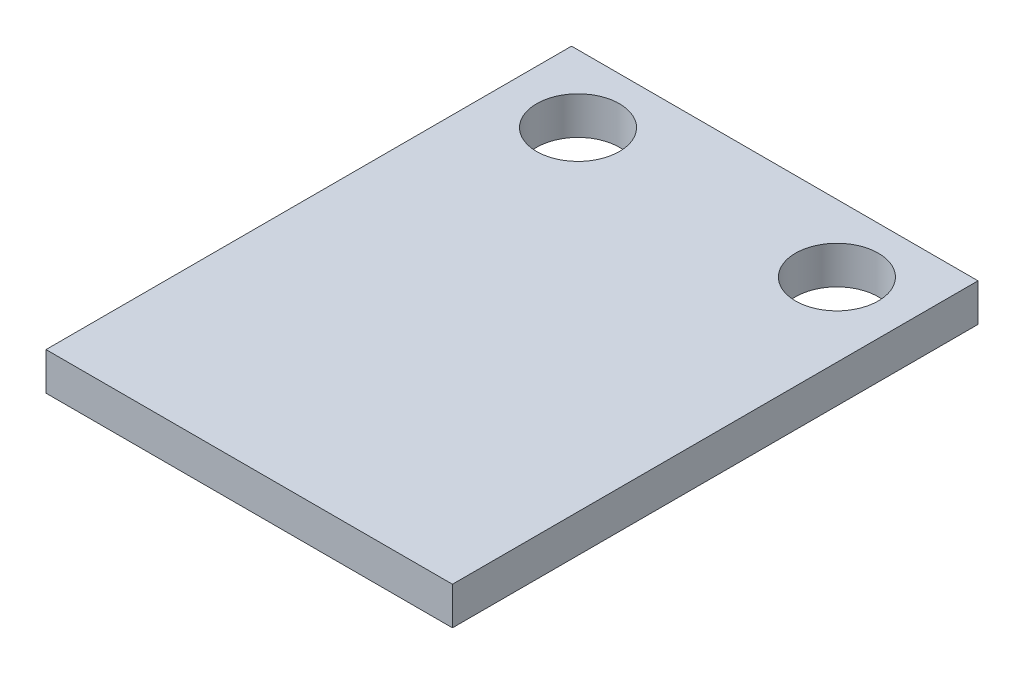
from build123d import *

# Parameters (mm, degrees)
SKETCH1_W           = 15.7
SKETCH1_H           = 20.3
SKETCH1_R           = 1.6
BOSS_EXTRUDE1_DEPTH = 1.46


with BuildPart() as part:
    # Sketch1 → Boss-Extrude1 (new body)
    with BuildSketch(Plane(origin=(0, 0, 0), x_dir=(1, 0, 0), z_dir=(0, 1, 0))):
        Rectangle(SKETCH1_W, SKETCH1_H)
        with Locations((-5, 7.55)):
            Circle(SKETCH1_R, mode=Mode.SUBTRACT)
        with Locations((5, 7.55)):
            Circle(SKETCH1_R, mode=Mode.SUBTRACT)
    extrude(amount=BOSS_EXTRUDE1_DEPTH)


solid = part.part
